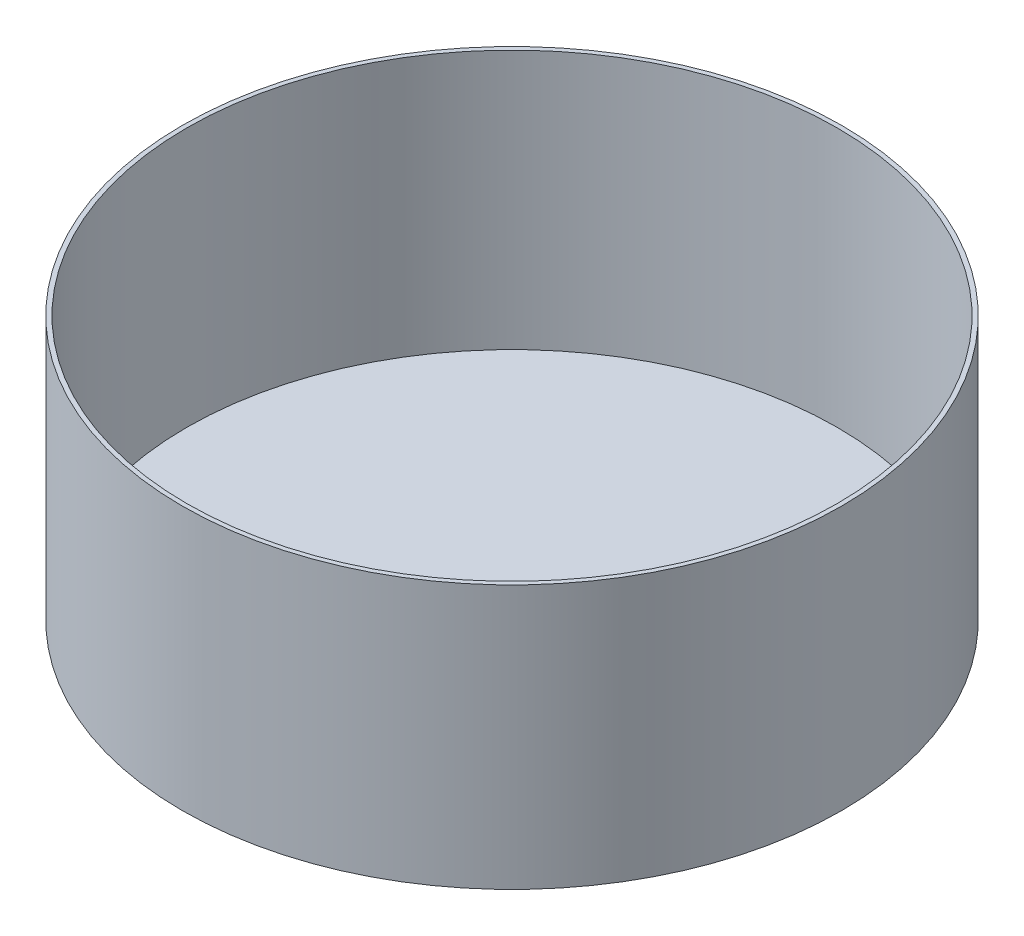
from build123d import *

# Parameters (mm, degrees)
SKETCH1_R           = 750
BOSS_EXTRUDE1_DEPTH = 600
SHELL1_T            = -10


with BuildPart() as part:
    # Sketch1 → Boss-Extrude1 (new body)
    with BuildSketch(Plane(origin=(0, 0, 0), x_dir=(1, 0, 0), z_dir=(0, 1, 0))):
        with Locations(Location((0, 0, 0), (0, 0, 270))):
            Circle(SKETCH1_R)
    extrude(amount=BOSS_EXTRUDE1_DEPTH)

    # Shell1
    shell1_openings = [part.faces().sort_by_distance(p)[0] for p in [
        (0, 600, 0),
    ]]
    offset(amount=SHELL1_T, openings=shell1_openings, kind=Kind.INTERSECTION)


solid = part.part
